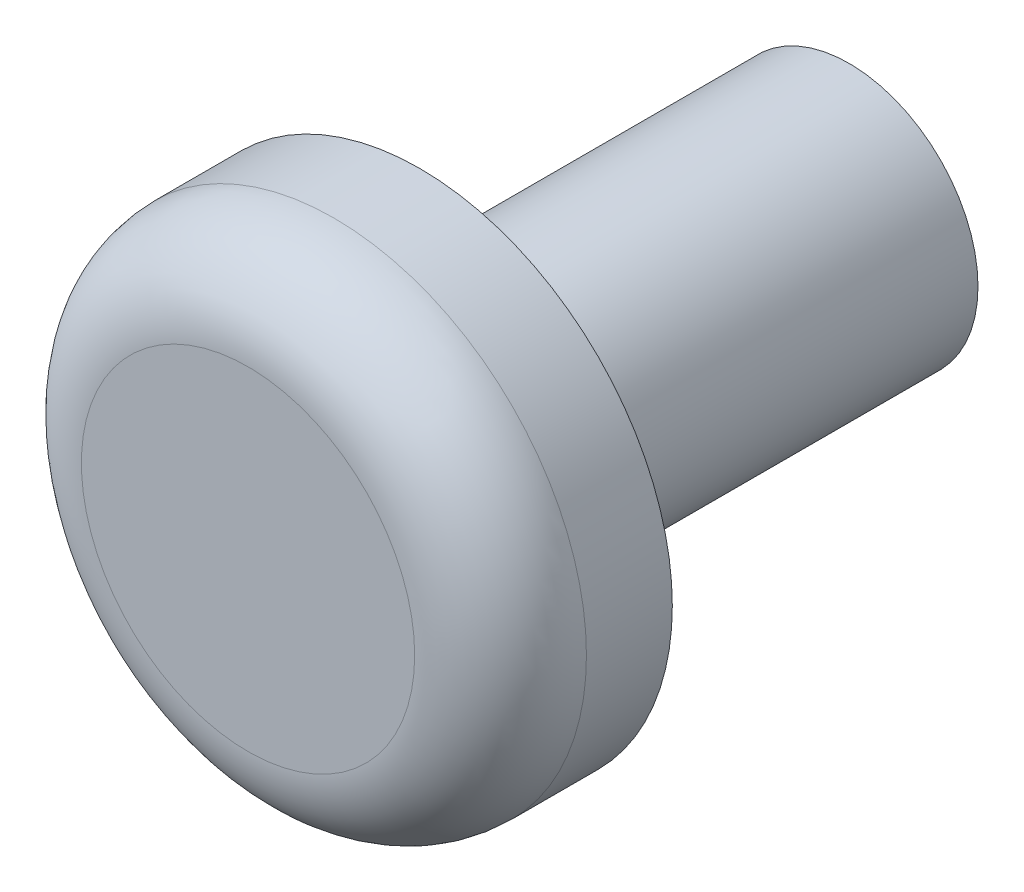
from build123d import *

# Parameters (mm, degrees)
SKETCH1_R           = 1.5
BOSS_EXTRUDE1_DEPTH = 5
SKETCH2_R           = 2.940597014
BOSS_EXTRUDE2_DEPTH = 2
FILLET1_R           = 1


with BuildPart() as part:
    # Sketch1 → Boss-Extrude1 (new body)
    with BuildSketch(Plane.XY):
        Circle(SKETCH1_R)
    extrude(amount=BOSS_EXTRUDE1_DEPTH)

    # Sketch2 → Boss-Extrude2 (add)
    with BuildSketch(Plane.XY.offset(5)):
        Circle(SKETCH2_R)
    extrude(amount=BOSS_EXTRUDE2_DEPTH)

    # Fillet1
    fillet1_edges = [part.edges().sort_by_distance(p)[0] for p in [
        (-2.940597014, 0, 7),
    ]]
    fillet(fillet1_edges, radius=FILLET1_R)


solid = part.part
